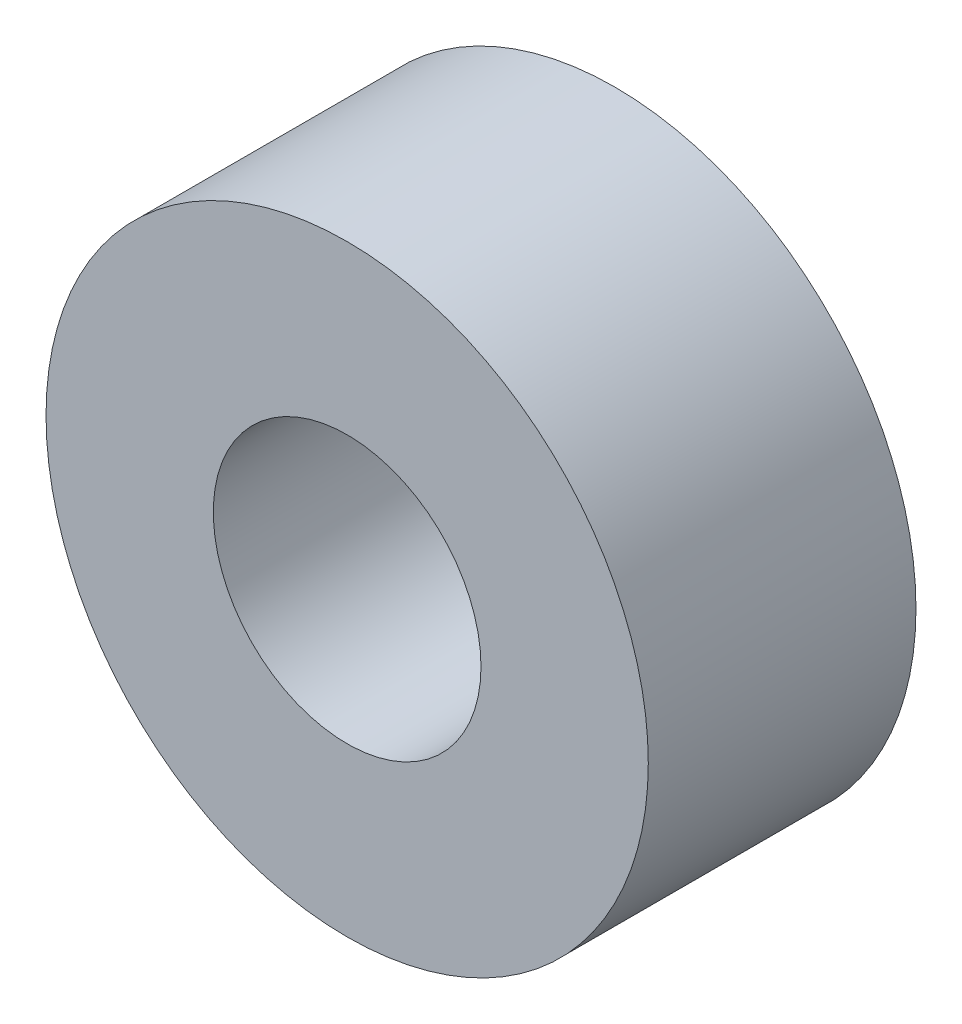
from build123d import *

# Parameters (mm, degrees)
SKETCH1_R           = 4.5
SKETCH1_R_2         = 2
BOSS_EXTRUDE1_DEPTH = 4


with BuildPart() as part:
    # Sketch1 → Boss-Extrude1 (new body)
    with BuildSketch(Plane.XY):
        Circle(SKETCH1_R)
        Circle(SKETCH1_R_2, mode=Mode.SUBTRACT)
    extrude(amount=BOSS_EXTRUDE1_DEPTH)


solid = part.part
